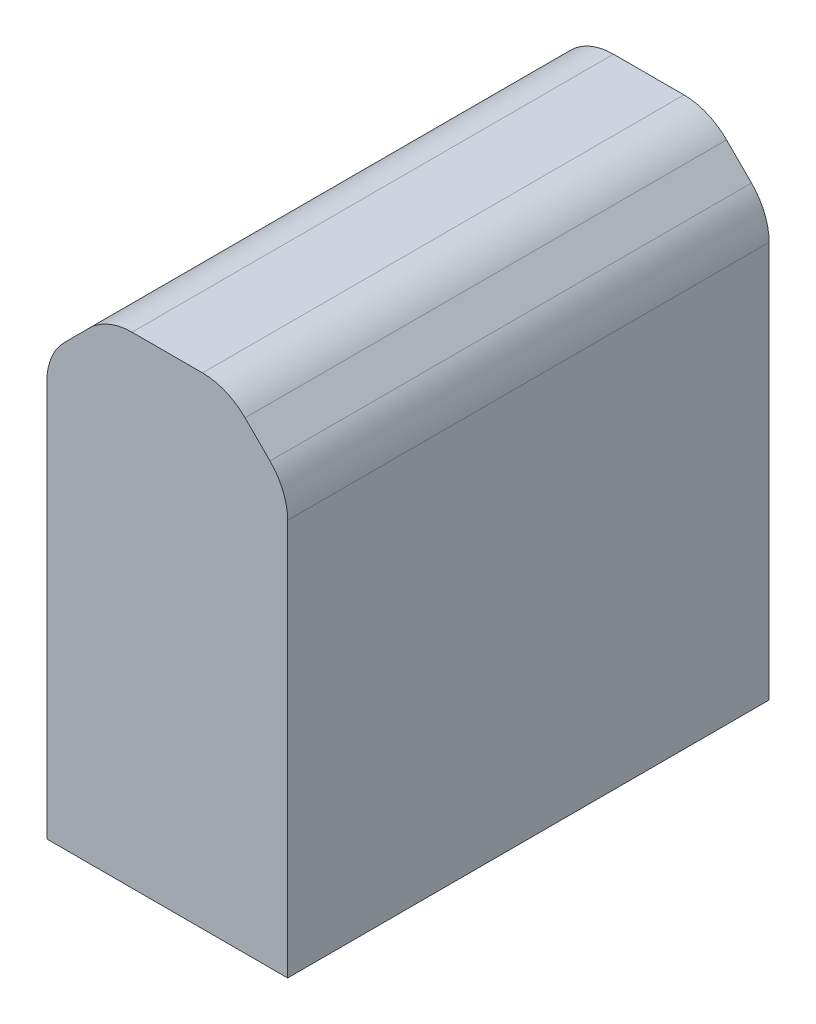
from build123d import *

# Parameters (mm, degrees)
SKETCH1_W           = 2
SKETCH1_H           = 4
BOSS_EXTRUDE1_DEPTH = 4
CHAMFER1_SIZE       = 0.5
FILLET1_R           = 0.5


with BuildPart() as part:
    # Sketch1 → Boss-Extrude1 (new body)
    with BuildSketch(Plane(origin=(0, 0, 0), x_dir=(1, 0, 0), z_dir=(0, 1, 0))):
        Rectangle(SKETCH1_W, SKETCH1_H)
    extrude(amount=BOSS_EXTRUDE1_DEPTH)

    # Chamfer1
    chamfer1_edges = [part.edges().sort_by_distance(p)[0] for p in [
        (-1, 4, 0),
        (1, 4, 0),
    ]]
    chamfer(chamfer1_edges, length=CHAMFER1_SIZE)

    # Fillet1
    fillet1_edges = [part.edges().sort_by_distance(p)[0] for p in [
        (0.5, 4, 0),
        (-0.5, 4, 0),
        (-1, 3.5, 0),
        (1, 3.5, 0),
    ]]
    fillet(fillet1_edges, radius=FILLET1_R)


solid = part.part
